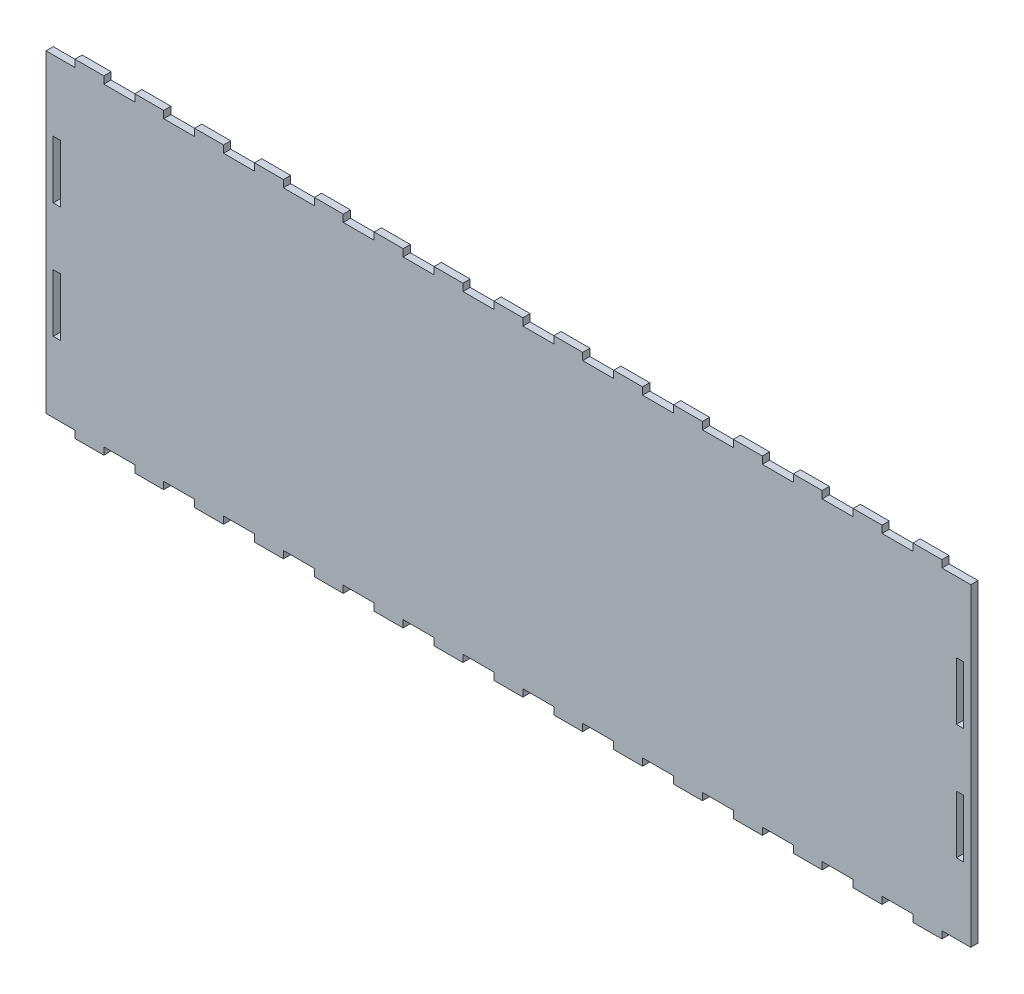
from build123d import *

# Parameters (mm, degrees)
SKETCH1_W           = 3.175
SKETCH1_H           = 25.4
BOSS_EXTRUDE1_DEPTH = 3.175


with BuildPart() as part:
    # Sketch1 → Boss-Extrude1 (new body)
    with BuildSketch(Plane.XY):
        Polygon((406.4, 0), (406.4, 138.0236), (393.7, 138.0236), (393.7, 141.1986), (381, 141.1986), (381, 138.0236), (367.392857143, 138.0236), (367.392857143, 141.1986), (354.692857143, 141.1986), (354.692857143, 138.0236), (341.085714286, 138.0236), (341.085714286, 141.1986), (328.385714286, 141.1986), (328.385714286, 138.0236), (314.778571429, 138.0236), (314.778571429, 141.1986), (302.078571429, 141.1986), (302.078571429, 138.0236), (288.471428571, 138.0236), (288.471428571, 141.1986), (275.771428571, 141.1986), (275.771428571, 138.0236), (262.164285714, 138.0236), (262.164285714, 141.1986), (249.464285714, 141.1986), (249.464285714, 138.0236), (235.857142857, 138.0236), (235.857142857, 141.1986), (223.157142857, 141.1986), (223.157142857, 138.0236), (209.55, 138.0236), (209.55, 141.1986), (196.85, 141.1986), (196.85, 138.0236), (183.242857143, 138.0236), (183.242857143, 141.1986), (170.542857143, 141.1986), (170.542857143, 138.0236), (156.935714286, 138.0236), (156.935714286, 141.1986), (144.235714286, 141.1986), (144.235714286, 138.0236), (130.628571429, 138.0236), (130.628571429, 141.1986), (117.928571429, 141.1986), (117.928571429, 138.0236), (104.321428571, 138.0236), (104.321428571, 141.1986), (91.621428571, 141.1986), (91.621428571, 138.0236), (78.014285714, 138.0236), (78.014285714, 141.1986), (65.314285714, 141.1986), (65.314285714, 138.0236), (51.707142857, 138.0236), (51.707142857, 141.1986), (39.007142857, 141.1986), (39.007142857, 138.0236), (25.4, 138.0236), (25.4, 141.1986), (12.7, 141.1986), (12.7, 138.0236), (0, 138.0236), (0, 0), (12.7, 0), (12.7, -3.175), (25.4, -3.175), (25.4, 0), (39.007142857, 0), (39.007142857, -3.175), (51.707142857, -3.175), (51.707142857, 0), (65.314285714, 0), (65.314285714, -3.175), (78.014285714, -3.175), (78.014285714, 0), (91.621428571, 0), (91.621428571, -3.175), (104.321428571, -3.175), (104.321428571, 0), (117.928571429, 0), (117.928571429, -3.175), (130.628571429, -3.175), (130.628571429, 0), (144.235714286, 0), (144.235714286, -3.175), (156.935714286, -3.175), (156.935714286, 0), (170.542857143, 0), (170.542857143, -3.175), (183.242857143, -3.175), (183.242857143, 0), (196.85, 0), (196.85, -3.175), (209.55, -3.175), (209.55, 0), (223.157142857, 0), (223.157142857, -3.175), (235.857142857, -3.175), (235.857142857, 0), (249.464285714, 0), (249.464285714, -3.175), (262.164285714, -3.175), (262.164285714, 0), (275.771428571, 0), (275.771428571, -3.175), (288.471428571, -3.175), (288.471428571, 0), (302.078571429, 0), (302.078571429, -3.175), (314.778571429, -3.175), (314.778571429, 0), (328.385714286, 0), (328.385714286, -3.175), (341.085714286, -3.175), (341.085714286, 0), (354.692857143, 0), (354.692857143, -3.175), (367.392857143, -3.175), (367.392857143, 0), (381, 0), (381, -3.175), (393.7, -3.175), (393.7, 0), align=None)
        with Locations((4.7625, 94.4118)):
            Rectangle(SKETCH1_W, SKETCH1_H, mode=Mode.SUBTRACT)
        with Locations((4.7625, 43.6118)):
            Rectangle(SKETCH1_W, SKETCH1_H, mode=Mode.SUBTRACT)
        with Locations((401.6375, 43.6118)):
            Rectangle(SKETCH1_W, SKETCH1_H, mode=Mode.SUBTRACT)
        with Locations((401.6375, 94.4118)):
            Rectangle(SKETCH1_W, SKETCH1_H, mode=Mode.SUBTRACT)
    extrude(amount=BOSS_EXTRUDE1_DEPTH)


solid = part.part
